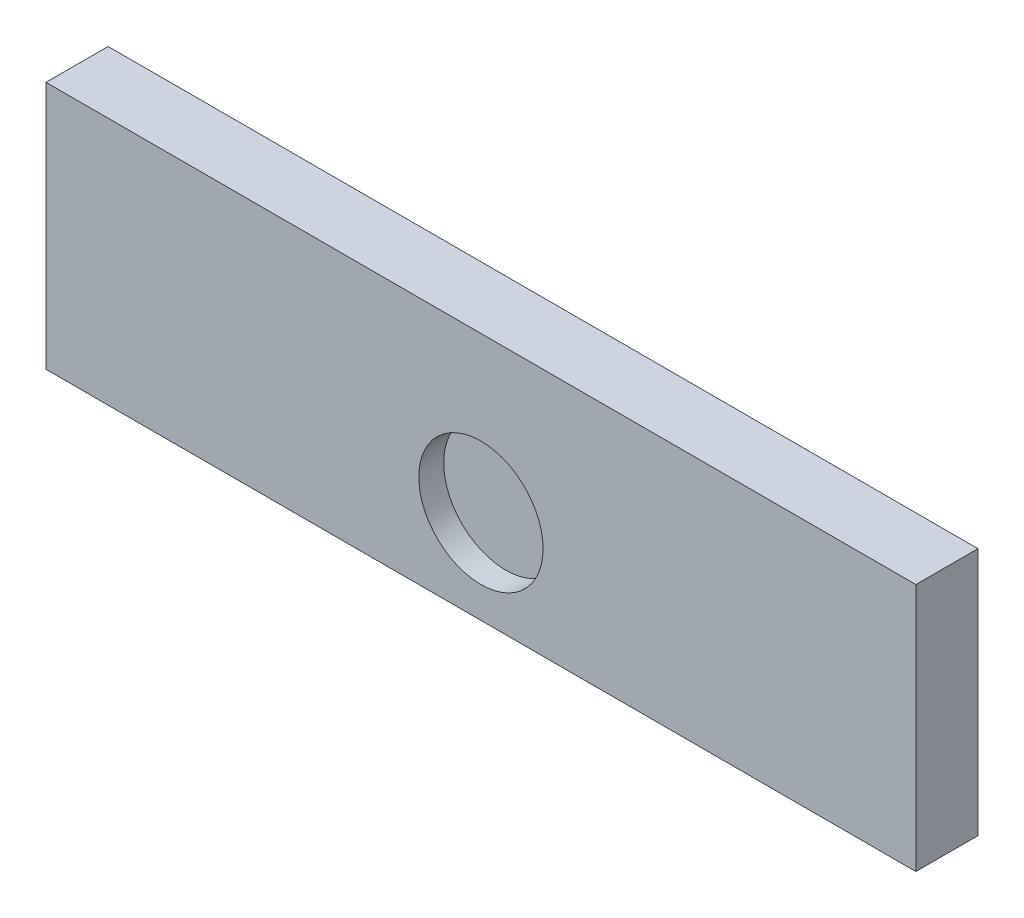
from build123d import *

# Parameters (mm, degrees)
SKETCH1_W           = 140
SKETCH1_H           = 40
BOSS_EXTRUDE1_DEPTH = 10
SKETCH3_R           = 10
CUT_EXTRUDE2_DEPTH  = 4


with BuildPart() as part:
    # Sketch1 → Boss-Extrude1 (new body)
    with BuildSketch(Plane.XY):
        Rectangle(SKETCH1_W, SKETCH1_H)
    extrude(amount=BOSS_EXTRUDE1_DEPTH)

    # Sketch3 → Cut-Extrude2 (cut)
    with BuildSketch(Plane.XY.offset(10)):
        with Locations((0, -5)):
            Circle(SKETCH3_R)
    extrude(amount=-CUT_EXTRUDE2_DEPTH, mode=Mode.SUBTRACT)


solid = part.part
